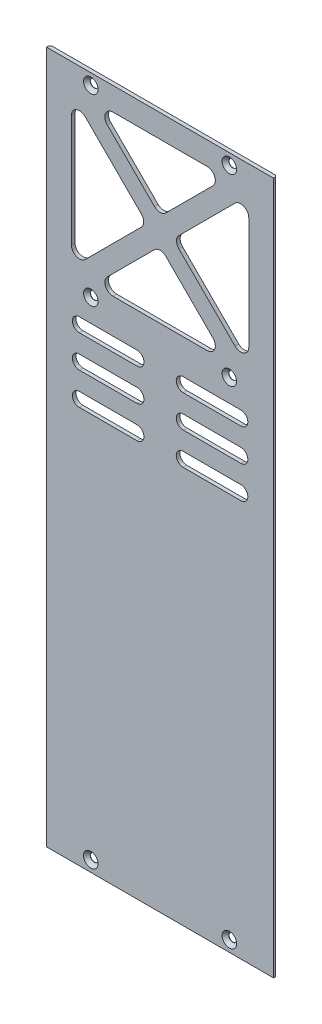
from build123d import *

# Parameters (mm, degrees)
SKETCH1_W                                       = 98.4125
SKETCH1_H                                       = 300
BOSS_EXTRUDE1_DEPTH                             = 0.79375
CHAMFER1_SIZE                                   = 0.79375
CUT_EXTRUDE1_DEPTH                              = 2.5875
FILLET1_R                                       = 3.5
CSK_FOR_M3_FLAT_HEAD_MACHINE_SCREW1_D           = 3.4
CSK_FOR_M3_FLAT_HEAD_MACHINE_SCREW1_DEPTH       = 7.596
CSK_FOR_M3_FLAT_HEAD_MACHINE_SCREW1_CSINK_D     = 6.3
CSK_FOR_M3_FLAT_HEAD_MACHINE_SCREW1_CSINK_ANGLE = 90
CSK_FOR_M3_FLAT_HEAD_MACHINE_SCREW1_TIP         = 1.021463052


with BuildPart() as part:
    # Sketch1 → Boss-Extrude1 (new body, symmetric)
    with BuildSketch(Plane.XY):
        Rectangle(SKETCH1_W, SKETCH1_H)
    extrude(amount=BOSS_EXTRUDE1_DEPTH, both=True)

    # Chamfer1
    chamfer1_edges = [part.edges().sort_by_distance(p)[0] for p in [
        (49.20625, 0, -0.79375),
        (-49.20625, 0, -0.79375),
    ]]
    chamfer(chamfer1_edges, length=CHAMFER1_SIZE)

    # Sketch2 → Cut-Extrude1 (cut, through all)
    with BuildSketch(Plane(origin=(0, 0, -0.79375), x_dir=(-1, 0, 0), z_dir=(0, 0, -1))):
        Polygon((28.868145751, 70.95), (0, 99.818145751), (-28.868145751, 70.95), align=None)
        Polygon((-38.4125, 72.719354249), (-38.4125, 138.230645751), (-5.656854249, 105.475), align=None)
        Polygon((28.868145751, 140), (-28.868145751, 140), (0, 111.131854249), align=None)
        Polygon((38.4125, 138.230645751), (38.4125, 72.719354249), (5.656854249, 105.475), align=None)
        with BuildLine():
            Line((10, 49.95), (35, 49.95))
            ThreePointArc((35, 49.95), (38, 52.95), (35, 55.95))
            Line((35, 55.95), (10, 55.95))
            ThreePointArc((10, 55.95), (7, 52.95), (10, 49.95))
        make_face()
        with BuildLine():
            Line((-35, 21.95), (-10, 21.95))
            ThreePointArc((-10, 21.95), (-7, 24.95), (-10, 27.95))
            Line((-10, 27.95), (-35, 27.95))
            ThreePointArc((-35, 27.95), (-38, 24.95), (-35, 21.95))
        make_face()
        with BuildLine():
            Line((-35, 55.95), (-10, 55.95))
            ThreePointArc((-10, 55.95), (-7, 52.95), (-10, 49.95))
            Line((-10, 49.95), (-35, 49.95))
            ThreePointArc((-35, 49.95), (-38, 52.95), (-35, 55.95))
        make_face()
        with BuildLine():
            Line((-35, 41.95), (-10, 41.95))
            ThreePointArc((-10, 41.95), (-7, 38.95), (-10, 35.95))
            Line((-10, 35.95), (-35, 35.95))
            ThreePointArc((-35, 35.95), (-38, 38.95), (-35, 41.95))
        make_face()
        with BuildLine():
            Line((10, 41.95), (35, 41.95))
            ThreePointArc((35, 41.95), (38, 38.95), (35, 35.95))
            Line((35, 35.95), (10, 35.95))
            ThreePointArc((10, 35.95), (7, 38.95), (10, 41.95))
        make_face()
        with BuildLine():
            Line((10, 27.95), (35, 27.95))
            ThreePointArc((35, 27.95), (38, 24.95), (35, 21.95))
            Line((35, 21.95), (10, 21.95))
            ThreePointArc((10, 21.95), (7, 24.95), (10, 27.95))
        make_face()
    extrude(amount=-CUT_EXTRUDE1_DEPTH, mode=Mode.SUBTRACT)

    # Fillet1
    fillet1_edges = [part.edges().sort_by_distance(p)[0] for p in [
        (38.4125, 72.719354249, 0),
        (38.4125, 138.230645751, 0),
        (5.656854249, 105.475, 0),
        (-38.4125, 138.230645751, 0),
        (-38.4125, 72.719354249, 0),
        (-5.656854249, 105.475, 0),
        (0, 99.818145751, 0),
        (-28.868145751, 70.95, 0),
        (28.868145751, 70.95, 0),
        (28.868145751, 140, 0),
        (-28.868145751, 140, 0),
        (0, 111.131854249, 0),
    ]]
    fillet(fillet1_edges, radius=FILLET1_R)

    # CSK for M3 Flat Head Machine Screw1
    with Locations(Plane.XY.offset(0.79375)):
        with Locations((-30, -145.225), (30, -145.225), (-30, 65.7), (30, 65.7), (30, 145.225), (-30, 145.225)):
            CounterSinkHole(CSK_FOR_M3_FLAT_HEAD_MACHINE_SCREW1_D / 2, CSK_FOR_M3_FLAT_HEAD_MACHINE_SCREW1_CSINK_D / 2, depth=CSK_FOR_M3_FLAT_HEAD_MACHINE_SCREW1_DEPTH, counter_sink_angle=CSK_FOR_M3_FLAT_HEAD_MACHINE_SCREW1_CSINK_ANGLE)
            with Locations((0, 0, -(CSK_FOR_M3_FLAT_HEAD_MACHINE_SCREW1_DEPTH + CSK_FOR_M3_FLAT_HEAD_MACHINE_SCREW1_TIP / 2))):  # 118° drill point
                Cone(0, CSK_FOR_M3_FLAT_HEAD_MACHINE_SCREW1_D / 2, CSK_FOR_M3_FLAT_HEAD_MACHINE_SCREW1_TIP, mode=Mode.SUBTRACT)


solid = part.part
